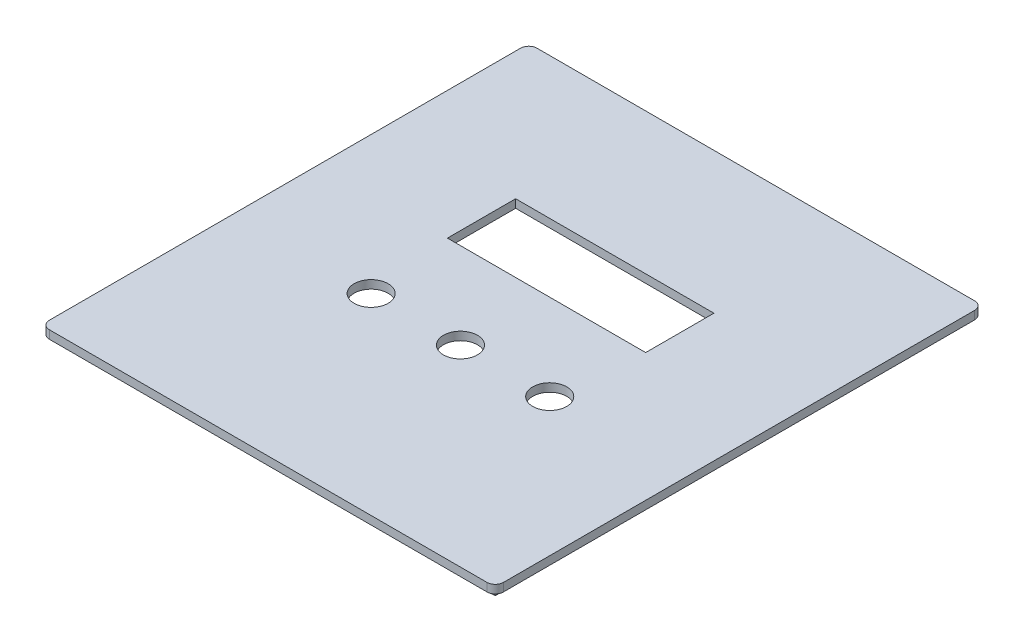
from build123d import *

# Parameters (mm, degrees)
SKETCH1_W           = 157.7
SKETCH1_H           = 169.84
SKETCH1_W_2         = 151.7
SKETCH1_H_2         = 163.84
BOSS_EXTRUDE1_DEPTH = 3
SKETCH2_W           = 164.3
SKETCH2_H           = 176.44
BOSS_EXTRUDE2_DEPTH = 3
SKETCH3_R           = 6.155
SKETCH3_W           = 71.73
SKETCH3_H           = 24.68
CUT_EXTRUDE1_DEPTH  = 3
FILLET1_R           = 3


with BuildPart() as part:
    # Sketch1 → Boss-Extrude1 (new body)
    with BuildSketch(Plane(origin=(0, 0, 0), x_dir=(1, 0, 0), z_dir=(0, 1, 0))):
        Rectangle(SKETCH1_W, SKETCH1_H)
        Rectangle(SKETCH1_W_2, SKETCH1_H_2, mode=Mode.SUBTRACT)
    extrude(amount=BOSS_EXTRUDE1_DEPTH)

    # Sketch2 → Boss-Extrude2 (add)
    with BuildSketch(Plane(origin=(0, 3, 0), x_dir=(1, 0, 0), z_dir=(0, 1, 0))):
        Rectangle(SKETCH2_W, SKETCH2_H)
    extrude(amount=BOSS_EXTRUDE2_DEPTH)

    # Sketch3 → Cut-Extrude1 (cut)
    with BuildSketch(Plane(origin=(0, 6, 0), x_dir=(1, 0, 0), z_dir=(0, 1, 0))):
        with Locations((0, -18.655)):
            Circle(SKETCH3_R)
        with Locations((32.31, -18.655)):
            Circle(SKETCH3_R)
        with Locations((-32.31, -18.655)):
            Circle(SKETCH3_R)
        with Locations((0, 24.84)):
            Rectangle(SKETCH3_W, SKETCH3_H)
    extrude(amount=-CUT_EXTRUDE1_DEPTH, mode=Mode.SUBTRACT)

    # Fillet1
    fillet1_edges = [part.edges().sort_by_distance(p)[0] for p in [
        (82.15, 4.5, 88.22),
        (82.15, 4.5, -88.22),
        (-82.15, 4.5, -88.22),
        (-82.15, 4.5, 88.22),
    ]]
    fillet(fillet1_edges, radius=FILLET1_R)


solid = part.part
